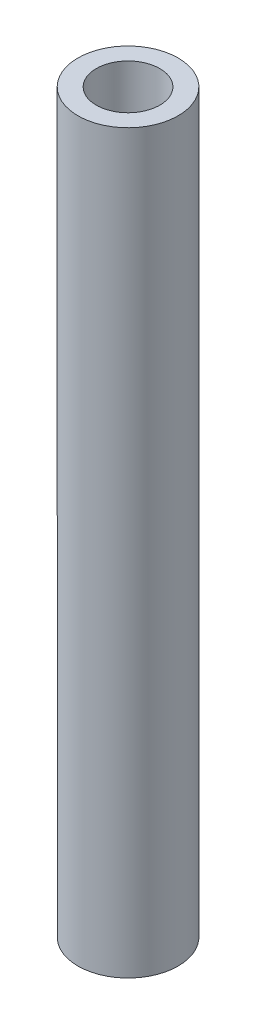
from build123d import *

# Parameters (mm, degrees)
SKETCH1_R               = 4.7625
SKETCH1_R_2             = 3.018976491
BOSS_EXTRUDE1_DEPTH     = 65
SKETCH5_W               = 36.473052953
SKETCH5_H               = 81.397778837
CUT_EXTRUDE2_DEPTH      = 5.7625
CUT_EXTRUDE2_DEPTH_BACK = 5.7625


with BuildPart() as part:
    # Sketch1 → Boss-Extrude1 (new body, symmetric)
    with BuildSketch(Plane(origin=(0, 0, 0), x_dir=(1, 0, 0), z_dir=(0, 1, 0))):
        Circle(SKETCH1_R)
        Circle(SKETCH1_R_2, mode=Mode.SUBTRACT)
    extrude(amount=BOSS_EXTRUDE1_DEPTH, both=True)

    # Sketch5 → Cut-Extrude2 (cut, two sides)
    with BuildSketch(Plane(origin=(0, 0, 0), x_dir=(0, 0, -1), z_dir=(1, 0, 0))) as cut_extrude2_sk:
        with Locations((-2.67750977, 45.698889419)):
            Rectangle(SKETCH5_W, SKETCH5_H)
    extrude(amount=CUT_EXTRUDE2_DEPTH, mode=Mode.SUBTRACT)
    extrude(cut_extrude2_sk.sketch, amount=-CUT_EXTRUDE2_DEPTH_BACK, mode=Mode.SUBTRACT)


solid = part.part
